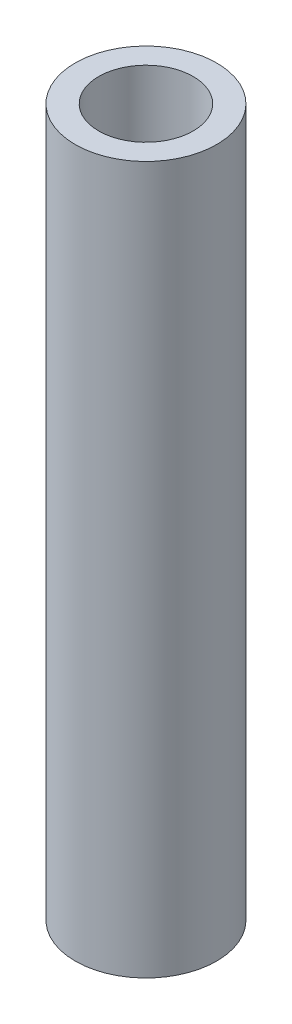
from build123d import *

# Parameters (mm, degrees)
SKETCH1_R           = 25
SKETCH1_R_2         = 16.7
BOSS_EXTRUDE1_DEPTH = 125


with BuildPart() as part:
    # Sketch1 → Boss-Extrude1 (new body, symmetric)
    with BuildSketch(Plane(origin=(0, 0, 0), x_dir=(1, 0, 0), z_dir=(0, 1, 0))):
        Circle(SKETCH1_R)
        Circle(SKETCH1_R_2, mode=Mode.SUBTRACT)
    extrude(amount=BOSS_EXTRUDE1_DEPTH, both=True)


solid = part.part
